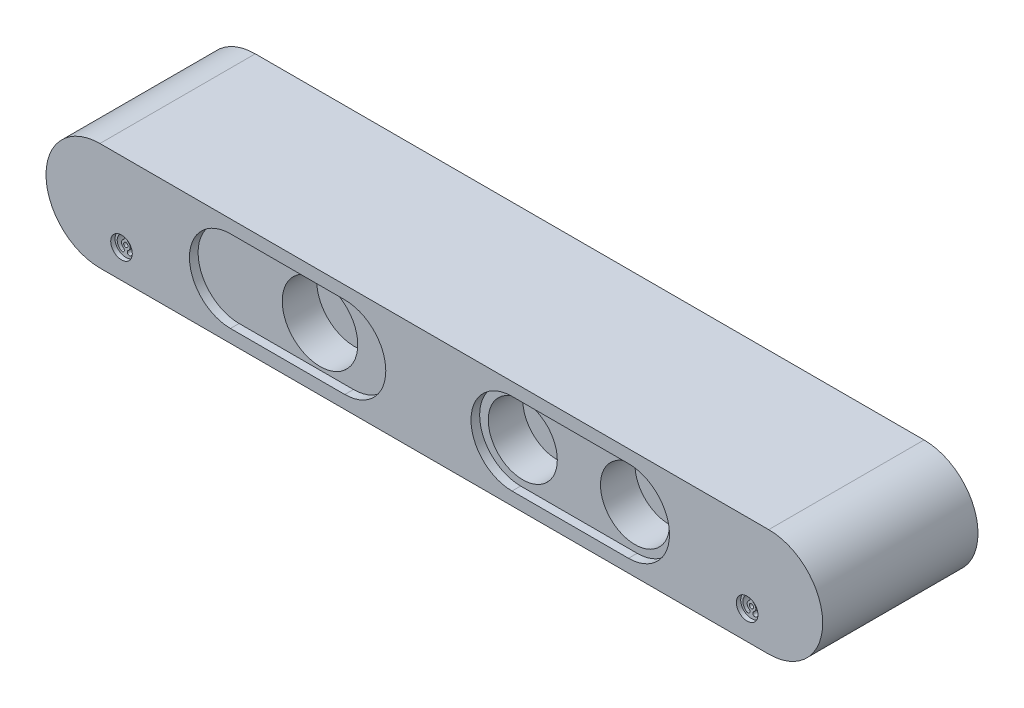
from build123d import *

# Parameters (mm, degrees)
BOSS_EXTRUDE1_DEPTH = 36
SKETCH3_R           = 8.75
SKETCH3_R_2         = 8
CUT_EXTRUDE1_DEPTH  = 10
CUT_EXTRUDE2_DEPTH  = 2
SKETCH5_R           = 2.5
CUT_EXTRUDE3_DEPTH  = 1
SKETCH6_R           = 0.5
CUT_EXTRUDE4_DEPTH  = 5


with BuildPart() as part:
    # Sketch1 → Boss-Extrude1 (new body)
    with BuildSketch(Plane.XY):
        with BuildLine():
            Line((-77.5, 12.5), (77.5, 12.5))
            ThreePointArc((77.5, 12.5), (90, 0), (77.5, -12.5))
            Line((77.5, -12.5), (-77.5, -12.5))
            ThreePointArc((-77.5, -12.5), (-90, 0), (-77.5, 12.5))
        make_face()
    extrude(amount=-BOSS_EXTRUDE1_DEPTH)

    # Sketch3 → Cut-Extrude1 (cut)
    with BuildSketch(Plane.XY):
        with Locations((-28.5, 0)):
            Circle(SKETCH3_R)
        with Locations((18.5, 0)):
            Circle(SKETCH3_R_2)
        with Locations((44.5, 0)):
            Circle(SKETCH3_R_2)
    extrude(amount=-CUT_EXTRUDE1_DEPTH, mode=Mode.SUBTRACT)

    # Sketch4 → Cut-Extrude2 (cut)
    with BuildSketch(Plane.XY):
        with BuildLine():
            Line((-47.25, 9.5), (-20.75, 9.5))
            ThreePointArc((-20.75, 9.5), (-11.25, 0), (-20.75, -9.5))
            Line((-20.75, -9.5), (-47.25, -9.5))
            ThreePointArc((-47.25, -9.5), (-56.75, 0), (-47.25, 9.5))
        make_face()
        with BuildLine():
            Line((18, 9.5), (45, 9.5))
            ThreePointArc((45, 9.5), (54.5, 0), (45, -9.5))
            Line((45, -9.5), (18, -9.5))
            ThreePointArc((18, -9.5), (8.5, 0), (18, 9.5))
        make_face()
    extrude(amount=-CUT_EXTRUDE2_DEPTH, mode=Mode.SUBTRACT)

    # Sketch5 → Cut-Extrude3 (cut)
    with BuildSketch(Plane.XY):
        with Locations((72.5, -5.85958214)):
            Circle(SKETCH5_R)
        with Locations((-72.5, -5.85958214)):
            Circle(SKETCH5_R)
    extrude(amount=-CUT_EXTRUDE3_DEPTH, mode=Mode.SUBTRACT)

    # Sketch6 → Cut-Extrude4 (cut)
    with BuildSketch(Plane.XY):
        with Locations((-72.5, -5.85958214)):
            Circle(SKETCH6_R)
        with Locations((72.5, -5.85958214)):
            Circle(SKETCH6_R)
        with BuildLine():
            ThreePointArc((-71.394458403, -7.526248807), (-70.5, -5.85958214), (-71.394458403, -4.192915474))
            ThreePointArc((-71.394458403, -4.192915474), (-72.087510469, -4.333196741), (-71.947229202, -5.026248807))
            ThreePointArc((-71.947229202, -5.026248807), (-71.5, -5.85958214), (-71.947229202, -6.692915474))
            ThreePointArc((-71.947229202, -6.692915474), (-72.087510469, -7.385967539), (-71.394458403, -7.526248807))
        make_face()
        with BuildLine():
            ThreePointArc((-73.605541597, -4.192915474), (-74.5, -5.85958214), (-73.605541597, -7.526248807))
            ThreePointArc((-73.605541597, -7.526248807), (-72.912489531, -7.385967539), (-73.052770798, -6.692915474))
            ThreePointArc((-73.052770798, -6.692915474), (-73.5, -5.85958214), (-73.052770798, -5.026248807))
            ThreePointArc((-73.052770798, -5.026248807), (-72.912489531, -4.333196741), (-73.605541597, -4.192915474))
        make_face()
        with BuildLine():
            ThreePointArc((73.605541597, -7.526248807), (74.5, -5.85958214), (73.605541597, -4.192915474))
            ThreePointArc((73.605541597, -4.192915474), (72.912489531, -4.333196741), (73.052770798, -5.026248807))
            ThreePointArc((73.052770798, -5.026248807), (73.5, -5.85958214), (73.052770798, -6.692915474))
            ThreePointArc((73.052770798, -6.692915474), (72.912489531, -7.385967539), (73.605541597, -7.526248807))
        make_face()
        with BuildLine():
            ThreePointArc((71.394458403, -4.192915474), (70.5, -5.85958214), (71.394458403, -7.526248807))
            ThreePointArc((71.394458403, -7.526248807), (72.087510469, -7.385967539), (71.947229202, -6.692915474))
            ThreePointArc((71.947229202, -6.692915474), (71.5, -5.85958214), (71.947229202, -5.026248807))
            ThreePointArc((71.947229202, -5.026248807), (72.087510469, -4.333196741), (71.394458403, -4.192915474))
        make_face()
    extrude(amount=-CUT_EXTRUDE4_DEPTH, mode=Mode.SUBTRACT)


solid = part.part
